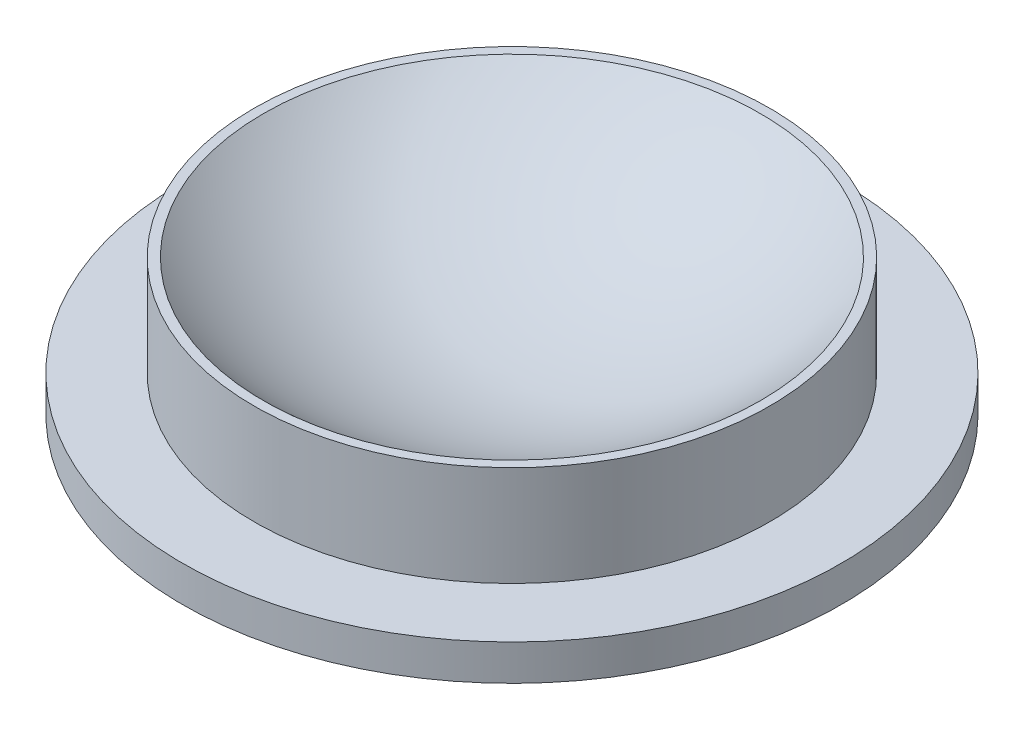
from build123d import *


with BuildPart() as part:
    # Эскиз1 → Повернуть2 (revolve)
    with BuildSketch(Plane.XY):
        with BuildLine():
            Line((0, -50), (0, -55))
            Line((0, -55), (46, -55))
            Line((46, -55), (46, -50))
            Line((46, -50), (36, -50))
            Line((36, -50), (36, -36))
            Line((36, -36), (34.698703146, -36))
            ThreePointArc((34.698703146, -36), (18.708286934, -46.368092477), (0, -50))
        make_face()
    revolve(axis=Axis((0, -50, 0), (0, -1, 0)))


solid = part.part
